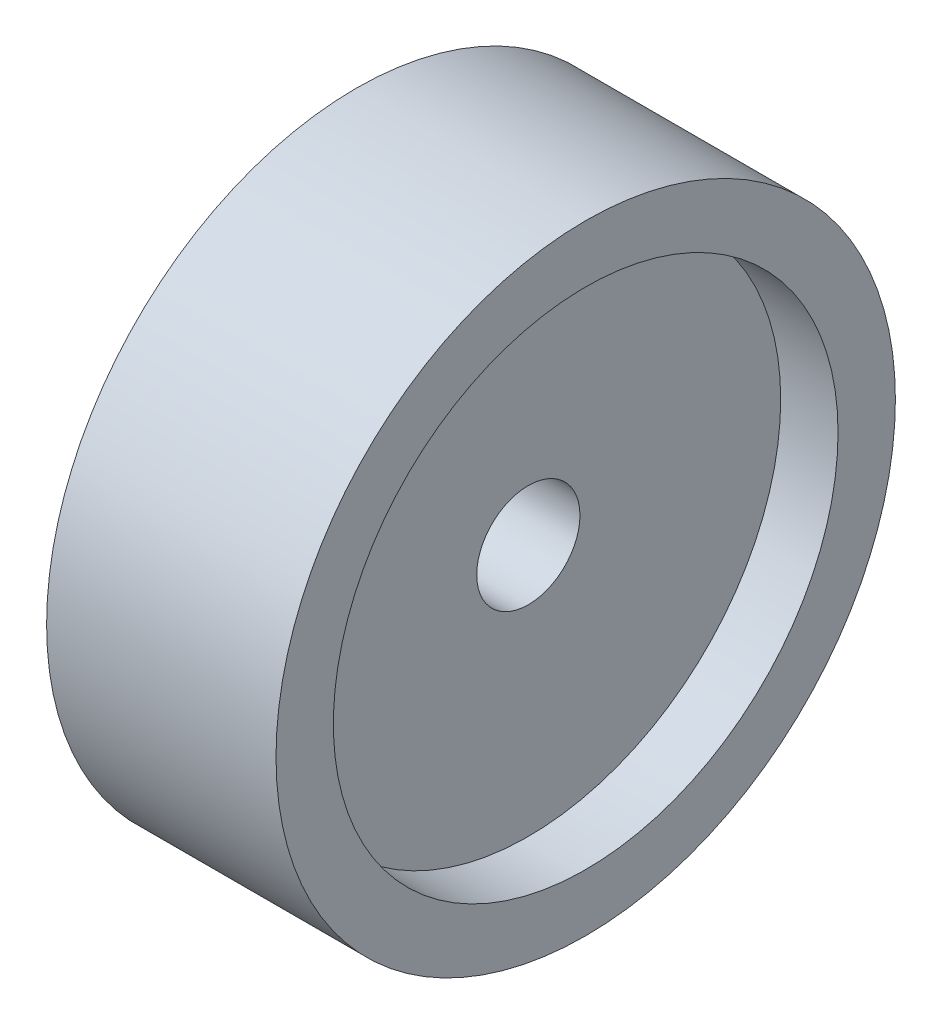
from build123d import *

# Parameters (mm, degrees)
ESQUISSE1_R             = 27
ESQUISSE1_R_2           = 4.5
EXTRUSION1_DEPTH        = 20
ESQUISSE2_R             = 22
ENL_V_MAT_EXTRU_1_DEPTH = 3
ESQUISSE3_R             = 22
ENL_V_MAT_EXTRU_2_DEPTH = 5


with BuildPart() as part:
    # Esquisse1 → Extrusion1 (new body)
    with BuildSketch(Plane(origin=(0, 0, 0), x_dir=(0, 0, -1), z_dir=(1, 0, 0))):
        Circle(ESQUISSE1_R)
        Circle(ESQUISSE1_R_2, mode=Mode.SUBTRACT)
    extrude(amount=EXTRUSION1_DEPTH)

    # Esquisse2 → Enlèv. mat.-Extru.1 (cut)
    with BuildSketch(Plane.ZY):
        Circle(ESQUISSE2_R)
    extrude(amount=-ENL_V_MAT_EXTRU_1_DEPTH, mode=Mode.SUBTRACT)

    # Esquisse3 → Enlèv. mat.-Extru.2 (cut)
    with BuildSketch(Plane(origin=(20, 0, 0), x_dir=(0, 0, -1), z_dir=(1, 0, 0))):
        Circle(ESQUISSE3_R)
    extrude(amount=-ENL_V_MAT_EXTRU_2_DEPTH, mode=Mode.SUBTRACT)


solid = part.part
